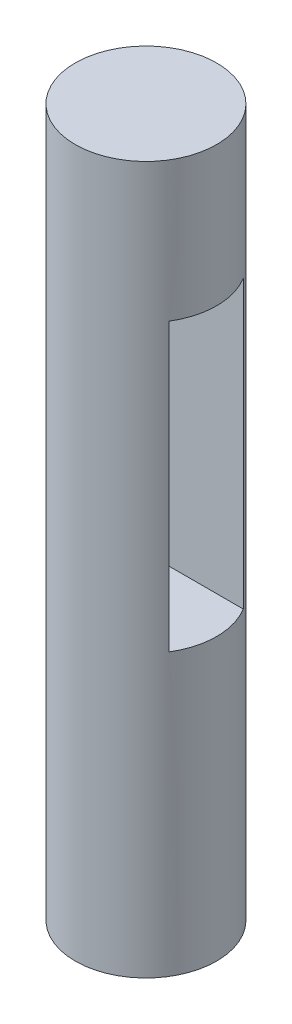
from build123d import *

# Parameters (mm, degrees)
SKETCH1_R           = 5
BOSS_EXTRUDE1_DEPTH = 50
SKETCH2_W           = 5.25
SKETCH2_H           = 20.25
CUT_EXTRUDE1_DEPTH  = 11


with BuildPart() as part:
    # Sketch1 → Boss-Extrude1 (new body)
    with BuildSketch(Plane(origin=(0, 0, 0), x_dir=(1, 0, 0), z_dir=(0, 1, 0))):
        Circle(SKETCH1_R)
    extrude(amount=BOSS_EXTRUDE1_DEPTH)

    # Sketch2 → Cut-Extrude1 (cut, through all)
    with BuildSketch(Plane(origin=(5, 0, 0), x_dir=(0, 0, -1), z_dir=(1, 0, 0))):
        with Locations((0, 30)):
            Rectangle(SKETCH2_W, SKETCH2_H)
    extrude(amount=-CUT_EXTRUDE1_DEPTH, mode=Mode.SUBTRACT)


solid = part.part
